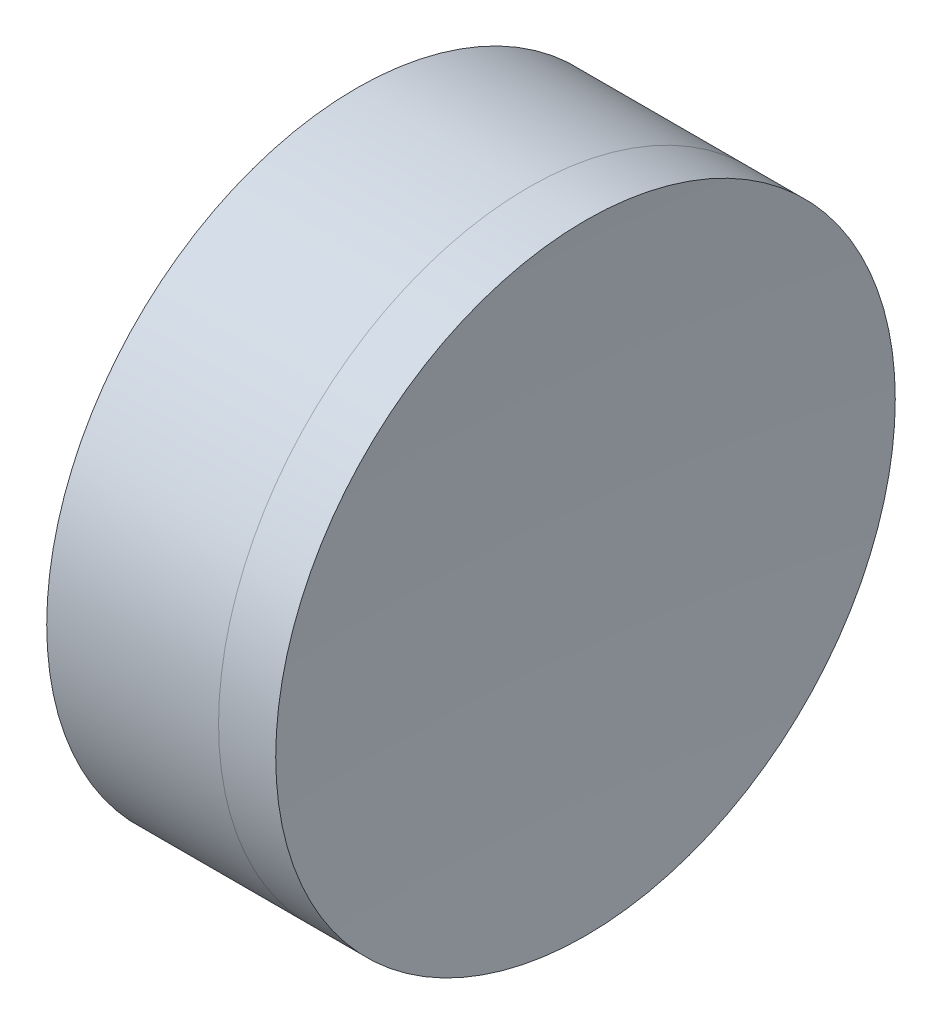
from build123d import *


with BuildPart() as part:
    # 草图1 one side → 旋转1 (revolve)
    with BuildSketch(Plane(origin=(0, 0, 0), x_dir=(1, 0, 0), z_dir=(0, 1, 0)), mode=Mode.PRIVATE) as revolve_1_sk:
        with BuildLine():
            Line((263.451481191, 12.7), (256.406386708, 12.7))
            ThreePointArc((256.406386708, 12.7), (258.246449506, 6.468121938), (258.86736326, 0))
            Line((258.86736326, 0), (260.86736326, 0))
            ThreePointArc((260.86736326, 0), (261.51994447, 6.480117003), (263.451481191, 12.7))
        make_face()
    revolve(revolve_1_sk.sketch.rotate(Axis((-0.816062176, 0, 0), (1, 0, 0)), 180), axis=Axis((-0.816062176, 0, 0), (1, 0, 0)))  # turned: the seam where the file's is


with BuildPart() as body_2:
    # 草图2 one side → 旋转3 (revolve)
    with BuildSketch(Plane(origin=(0, 0, 0), x_dir=(1, 0, 0), z_dir=(0, 1, 0)), mode=Mode.PRIVATE) as revolve_3_sk:
        with BuildLine():
            Line((265.79408655, 12.7), (263.451481191, 12.7))
            ThreePointArc((263.451481191, 12.7), (261.51994447, 6.480117003), (260.86736326, 0))
            Line((260.86736326, 0), (265.36736326, 0))
            ThreePointArc((265.36736326, 0), (265.474074176, 6.353583492), (265.79408655, 12.7))
        make_face()
    revolve(revolve_3_sk.sketch.rotate(Axis((256.406386708, 0, 0), (1, 0, 0)), 180), axis=Axis((256.406386708, 0, 0), (1, 0, 0)))  # turned: the seam where the file's is


solid = Compound([part.part, body_2.part])
